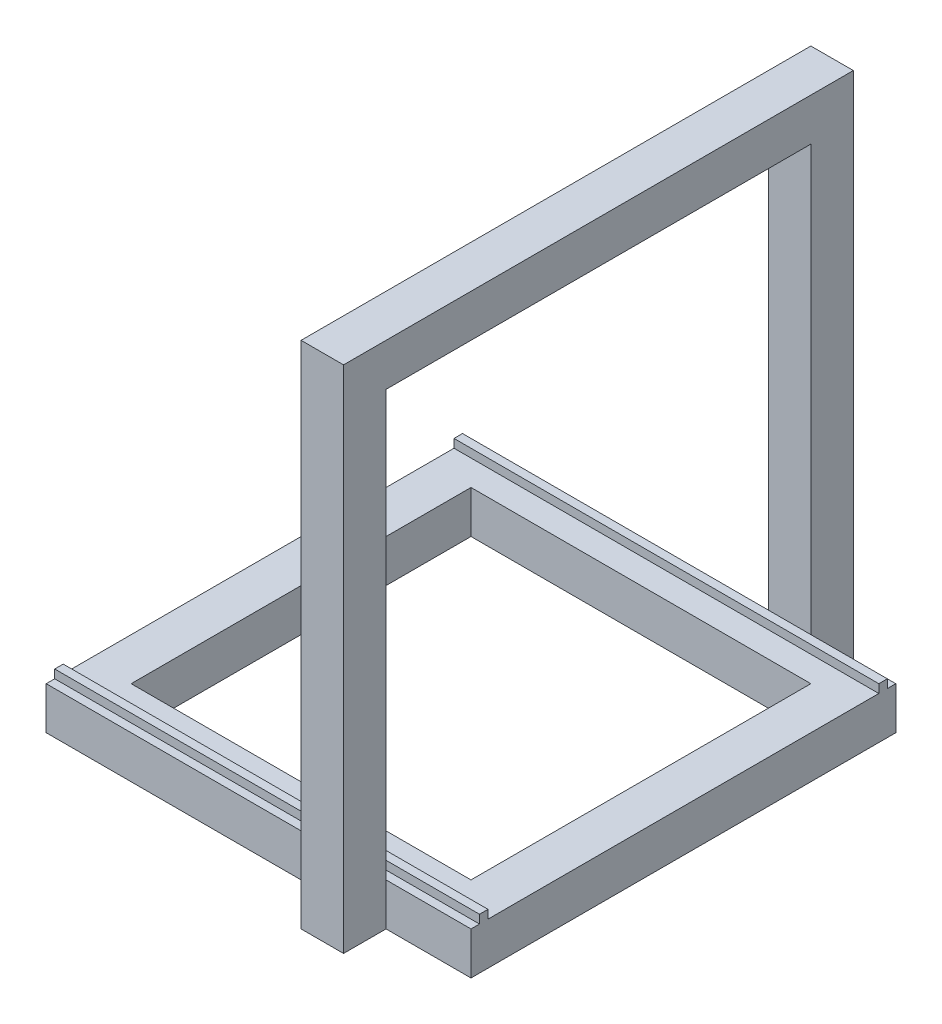
from build123d import *

# Parameters (mm, degrees)
SKETCH2_W           = 500
SKETCH2_H           = 500
BOSS_EXTRUDE1_DEPTH = 50
SKETCH7_W           = 400
SKETCH7_H           = 400
CUT_EXTRUDE1_DEPTH  = 550
SKETCH8_W           = 500
SKETCH8_H           = 10
BOSS_EXTRUDE2_DEPTH = 10
SKETCH9_W           = 50
SKETCH9_H           = 50
BOSS_EXTRUDE3_DEPTH = 550
SKETCH10_W          = 50
SKETCH10_H          = 50
BOSS_EXTRUDE4_DEPTH = 600


with BuildPart() as part:
    # Sketch2 → Boss-Extrude1 (new body)
    with BuildSketch(Plane(origin=(0, 0, 0), x_dir=(1, 0, 0), z_dir=(0, 1, 0))):
        Rectangle(SKETCH2_W, SKETCH2_H)
    extrude(amount=BOSS_EXTRUDE1_DEPTH)

    # Sketch7 → Cut-Extrude1 (cut)
    with BuildSketch(Plane(origin=(0, 50, 0), x_dir=(1, 0, 0), z_dir=(0, 1, 0))):
        Rectangle(SKETCH7_W, SKETCH7_H)
    extrude(amount=-CUT_EXTRUDE1_DEPTH, mode=Mode.SUBTRACT)

    # Sketch8 → Boss-Extrude2 (add)
    with BuildSketch(Plane(origin=(0, 50, 0), x_dir=(1, 0, 0), z_dir=(0, 1, 0))):
        with Locations((0, 235)):
            Rectangle(SKETCH8_W, SKETCH8_H)
        with Locations((0, -235)):
            Rectangle(SKETCH8_W, SKETCH8_H)
    extrude(amount=BOSS_EXTRUDE2_DEPTH)

    # Sketch9 → Boss-Extrude3 (add)
    with BuildSketch(Plane.XZ):
        with Locations((125, -275)):
            Rectangle(SKETCH9_W, SKETCH9_H)
        with Locations((125, 275)):
            Rectangle(SKETCH9_W, SKETCH9_H)
    extrude(amount=-BOSS_EXTRUDE3_DEPTH)

    # Sketch10 → Boss-Extrude4 (add)
    with BuildSketch(Plane.XY.offset(300)):
        with Locations((125, 575)):
            Rectangle(SKETCH10_W, SKETCH10_H)
    extrude(amount=-BOSS_EXTRUDE4_DEPTH)


solid = part.part
